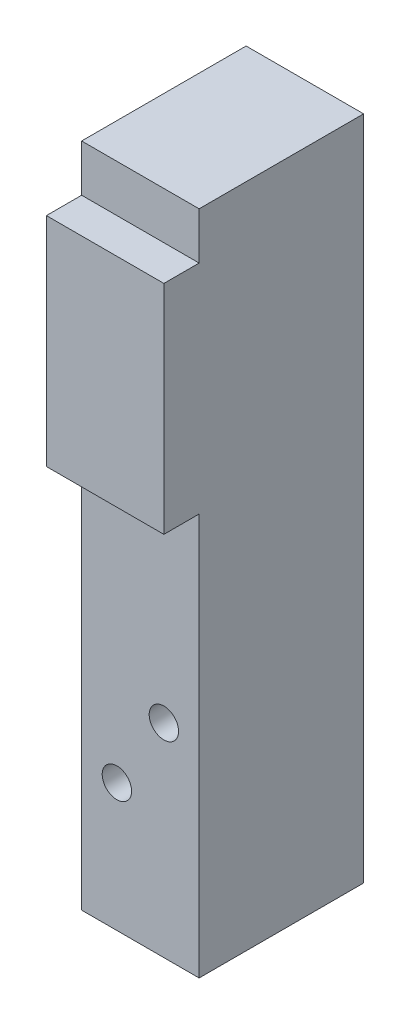
from build123d import *

# Parameters (mm, degrees)
SKETCH1_W                 = 10
SKETCH1_H                 = 14
EXTRUDE1_DEPTH            = 56.7
SKETCH2_W                 = 10
SKETCH2_H                 = 18.498
EXTRUDE2_DEPTH            = 3
M3X0_5_TAPPED_HOLE1_D     = 2.5
M3X0_5_TAPPED_HOLE1_DEPTH = 7.5
M3X0_5_TAPPED_HOLE1_TIP   = 0.220408726
M3X0_5_TAPPED_HOLE2_D     = 2.5
M3X0_5_TAPPED_HOLE2_DEPTH = 7.5
M3X0_5_TAPPED_HOLE2_TIP   = 0.220408726


with BuildPart() as part:
    # Sketch1 → Extrude1 (new body)
    with BuildSketch(Plane(origin=(0, 0, 0), x_dir=(1, 0, 0), z_dir=(0, 1, 0))):
        Rectangle(SKETCH1_W, SKETCH1_H)
    extrude(amount=-EXTRUDE1_DEPTH)

    # Sketch2 → Extrude2 (add)
    with BuildSketch(Plane.XY.offset(7)):
        with Locations((0, -13.249)):
            Rectangle(SKETCH2_W, SKETCH2_H)
    extrude(amount=EXTRUDE2_DEPTH)

    # M3x0.5 Tapped Hole1
    with Locations(Plane(origin=(0, -36.2, -7), x_dir=(-1, 0, 0), z_dir=(0, 0, -1))):
        with Locations((0, 0), (0, -6.4), (0, -12.8)):
            Hole(M3X0_5_TAPPED_HOLE1_D / 2, depth=M3X0_5_TAPPED_HOLE1_DEPTH)
            with Locations((0, 0, -(M3X0_5_TAPPED_HOLE1_DEPTH + M3X0_5_TAPPED_HOLE1_TIP / 2))):  # 160° drill point
                Cone(0, M3X0_5_TAPPED_HOLE1_D / 2, M3X0_5_TAPPED_HOLE1_TIP, mode=Mode.SUBTRACT)

    # M3x0.5 Tapped Hole2
    with Locations(Plane.XY.offset(7)):
        with Locations((2, -39.4), (-2, -45.81)):
            Hole(M3X0_5_TAPPED_HOLE2_D / 2, depth=M3X0_5_TAPPED_HOLE2_DEPTH)
            with Locations((0, 0, -(M3X0_5_TAPPED_HOLE2_DEPTH + M3X0_5_TAPPED_HOLE2_TIP / 2))):  # 160° drill point
                Cone(0, M3X0_5_TAPPED_HOLE2_D / 2, M3X0_5_TAPPED_HOLE2_TIP, mode=Mode.SUBTRACT)


solid = part.part
